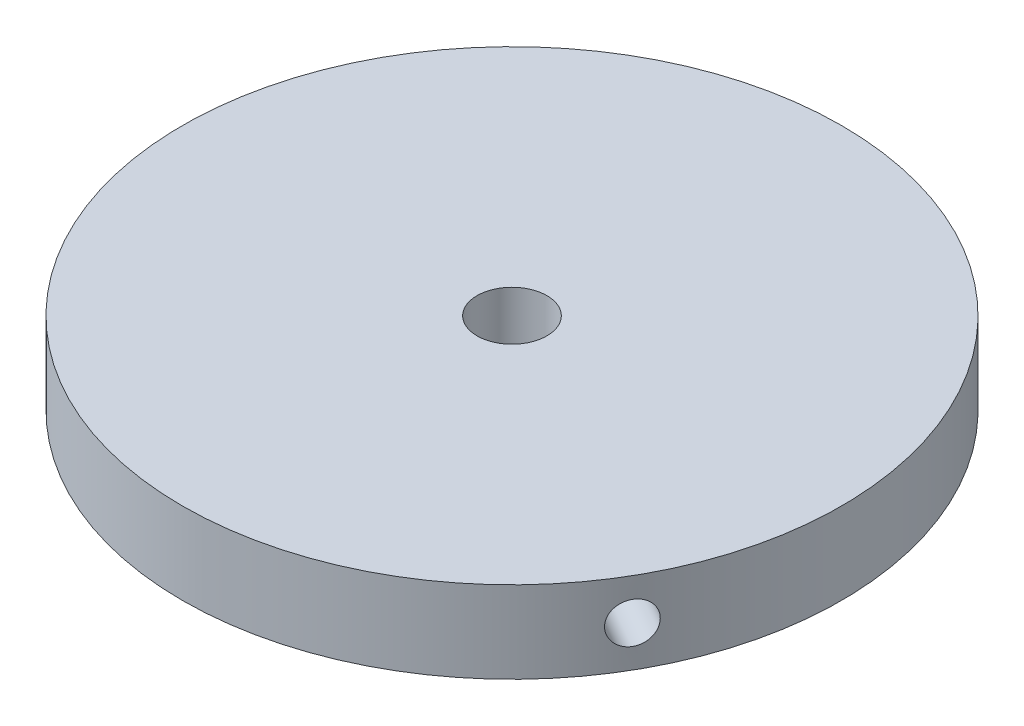
from build123d import *

# Parameters (mm, degrees)
SKETCH1_R           = 38.354
BOSS_EXTRUDE1_DEPTH = 9.525
SKETCH4_R           = 2.3749
CUT_EXTRUDE2_DEPTH  = 6.35
CIRPATTERN1_COUNT   = 3
SKETCH6_R           = 4.064
CUT_EXTRUDE4_DEPTH  = 56.070720663


with BuildPart() as part:
    # Sketch1 → Boss-Extrude1 (new body)
    with BuildSketch(Plane(origin=(0, 0, 0), x_dir=(1, 0, 0), z_dir=(0, 1, 0))):
        Circle(SKETCH1_R)
    extrude(amount=BOSS_EXTRUDE1_DEPTH)

    # Sketch4 → Cut-Extrude2 (cut)
    with BuildSketch(Plane(origin=(-33.215538337, 0, 19.177), x_dir=(0, -1, 0), z_dir=(-0.8660254037844433, 0, 0.49999999999999195))):
        with Locations((-4.7625, 0)):
            Circle(SKETCH4_R)
    cut_extrude2 = extrude(amount=-CUT_EXTRUDE2_DEPTH, mode=Mode.SUBTRACT)

    # CirPattern1: Cut-Extrude2 ×3 about axis
    cirpattern1_axis = Axis((0, 10.00125, 0), (0, -1, 0))
    for i in range(1, CIRPATTERN1_COUNT):
        add(cut_extrude2.rotate(cirpattern1_axis, i * 360 / CIRPATTERN1_COUNT), mode=Mode.SUBTRACT)

    # Sketch6 → Cut-Extrude4 (cut, through all)
    with BuildSketch(Plane(origin=(0, 9.525, 0), x_dir=(1, 0, 0), z_dir=(0, 1, 0))):
        Circle(SKETCH6_R)
    extrude(amount=-CUT_EXTRUDE4_DEPTH, mode=Mode.SUBTRACT)


solid = part.part
